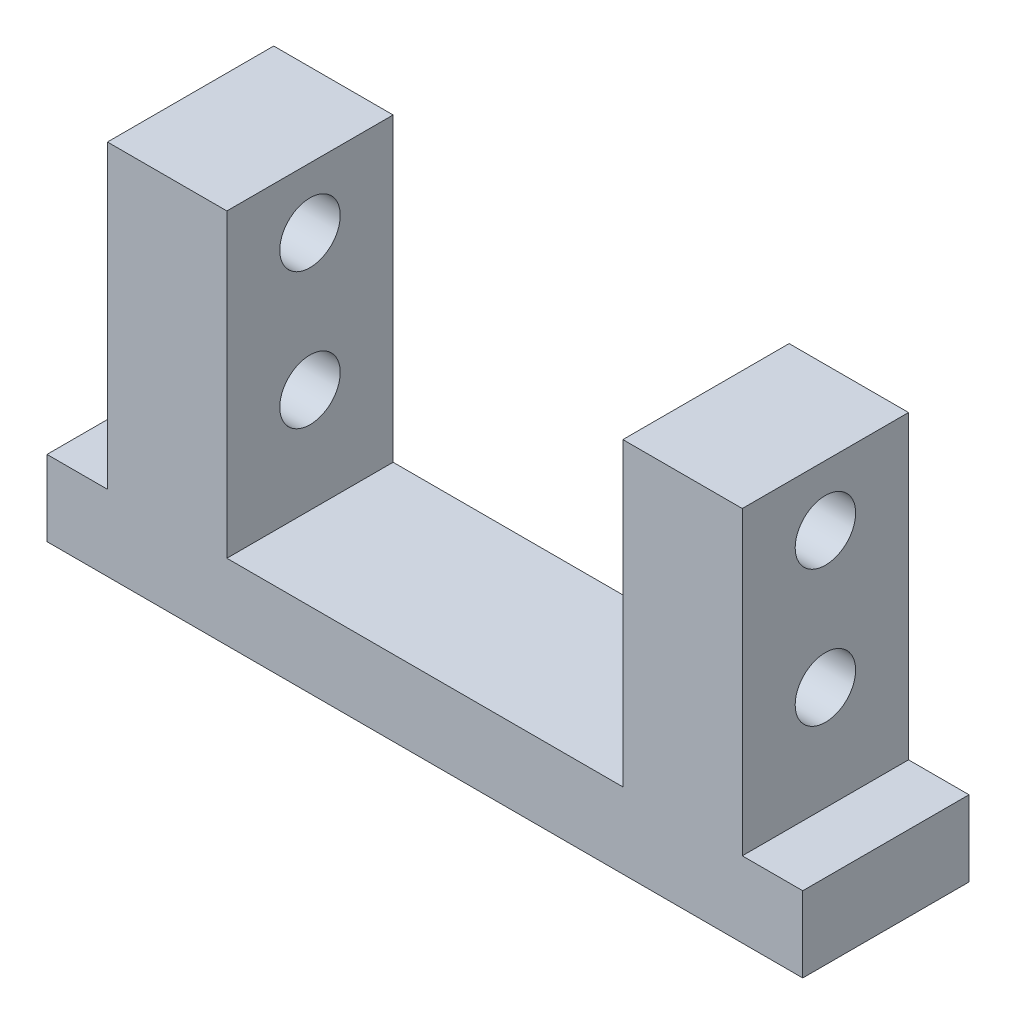
from build123d import *

# Parameters (mm, degrees)
SKETCH1_W           = 100
SKETCH1_H           = 22
BOSS_EXTRUDE1_DEPTH = 10
SKETCH2_W           = 84
SKETCH2_H           = 22
BOSS_EXTRUDE2_DEPTH = 39.8
SKETCH3_W           = 52.4
SKETCH3_H           = 22
CUT_EXTRUDE1_DEPTH  = 39.8
SKETCH4_R           = 4
CUT_EXTRUDE2_DEPTH  = 93


with BuildPart() as part:
    # Sketch1 → Boss-Extrude1 (new body)
    with BuildSketch(Plane(origin=(0, 0, 0), x_dir=(1, 0, 0), z_dir=(0, 1, 0))):
        Rectangle(SKETCH1_W, SKETCH1_H)
    extrude(amount=BOSS_EXTRUDE1_DEPTH)

    # Sketch2 → Boss-Extrude2 (add)
    with BuildSketch(Plane(origin=(0, 10, 0), x_dir=(1, 0, 0), z_dir=(0, 1, 0))):
        Rectangle(SKETCH2_W, SKETCH2_H)
    extrude(amount=BOSS_EXTRUDE2_DEPTH)

    # Sketch3 → Cut-Extrude1 (cut)
    with BuildSketch(Plane(origin=(0, 49.8, 0), x_dir=(1, 0, 0), z_dir=(0, 1, 0))):
        Rectangle(SKETCH3_W, SKETCH3_H)
    extrude(amount=-CUT_EXTRUDE1_DEPTH, mode=Mode.SUBTRACT)

    # Sketch4 → Cut-Extrude2 (cut, through all)
    with BuildSketch(Plane.ZY.offset(42)):
        with Locations((0, 41.8)):
            Circle(SKETCH4_R)
        with Locations((0, 23.8)):
            Circle(SKETCH4_R)
    extrude(amount=-CUT_EXTRUDE2_DEPTH, mode=Mode.SUBTRACT)


solid = part.part
